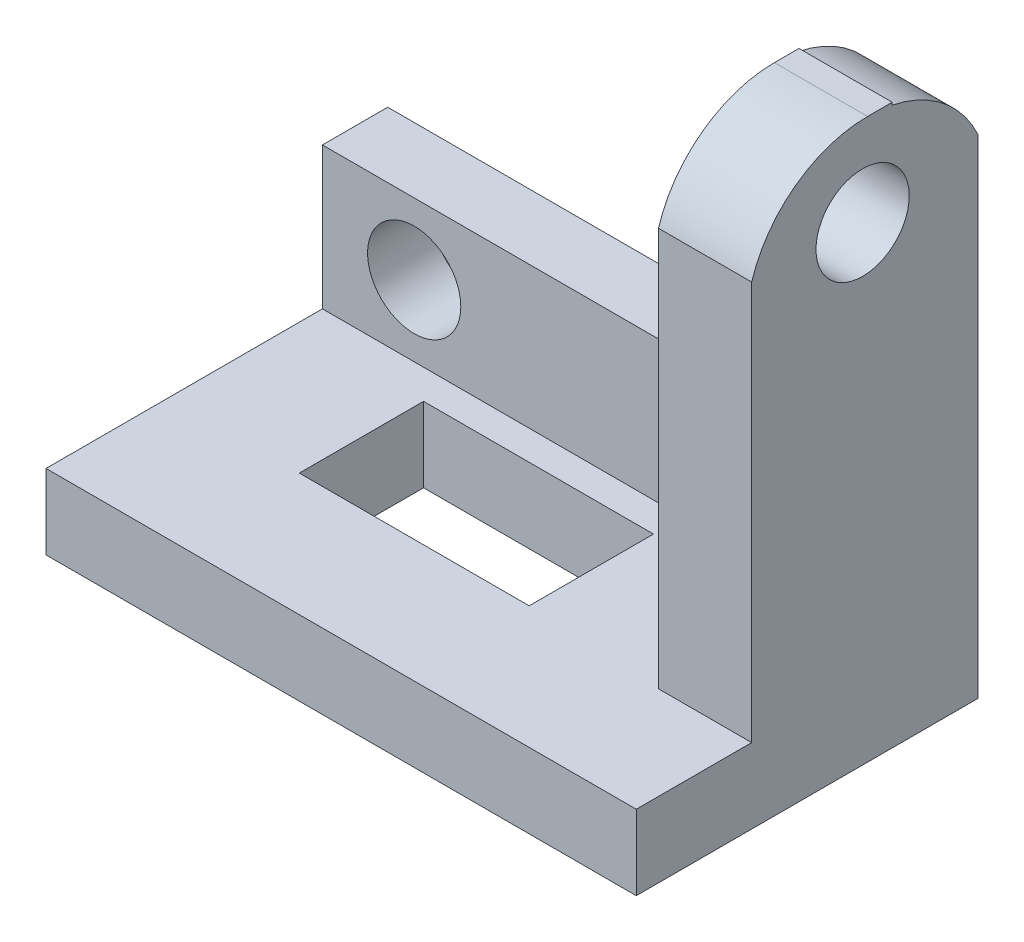
from build123d import *

# Parameters (mm, degrees)
SKETCH9_W           = 95
SKETCH9_H           = 55
BOSS_EXTRUDE1_DEPTH = 90
CUT_EXTRUDE5_DEPTH  = 100
SKETCH12_W          = 60.486878253
SKETCH12_H          = 73.853608548
CUT_EXTRUDE7_DEPTH  = 80
SKETCH13_W          = 80
SKETCH13_H          = 25.917714192
CUT_EXTRUDE8_DEPTH  = 22.845479
FILLET1_R           = 20
SKETCH16_R          = 7.5
CUT_EXTRUDE9_DEPTH  = 30
SKETCH17_W          = 37
SKETCH17_H          = 20
CUT_EXTRUDE10_DEPTH = 30
SKETCH18_R          = 7.5
CUT_EXTRUDE11_DEPTH = 30


with BuildPart() as part:
    # Sketch9 → Boss-Extrude1 (new body)
    with BuildSketch(Plane(origin=(0, 0, 0), x_dir=(1, 0, 0), z_dir=(0, 1, 0))):
        with Locations((9.391117479, -20.408309456)):
            Rectangle(SKETCH9_W, SKETCH9_H)
    extrude(amount=-BOSS_EXTRUDE1_DEPTH)

    # Sketch10 → Cut-Extrude5 (cut)
    with BuildSketch(Plane(origin=(56.891117479, 0, 0), x_dir=(0, 0, -1), z_dir=(1, 0, 0))):
        with BuildLine():
            ThreePointArc((-6.717440326, -0.405285552), (1.502612431, -4.261054452), (7.091690544, -11.416362061))
            Line((7.091690544, -11.416362061), (7.091690544, 0))
            Line((7.091690544, 0), (-6.717440326, 0))
            Line((-6.717440326, 0), (-6.717440326, -0.405285552))
        make_face()
        with BuildLine():
            Line((-47.908309456, -77.945973927), (-29.335605617, -77.945973927))
            Line((-29.335605617, -77.945973927), (-29.335605617, -13.754463437))
            ThreePointArc((-29.335605617, -13.754463437), (-22.266542801, -3.810210472), (-10.675938318, 0))
            Line((-10.675938318, 0), (-47.908309456, 0))
            Line((-47.908309456, 0), (-47.908309456, -77.945973927))
        make_face()
    extrude(amount=-CUT_EXTRUDE5_DEPTH, mode=Mode.SUBTRACT)

    # Sketch12 → Cut-Extrude7 (cut)
    with BuildSketch(Plane.ZY.offset(38.108882521)):
        with Locations((7.902207673, -18.173690635)):
            Rectangle(SKETCH12_W, SKETCH12_H)
    extrude(amount=-CUT_EXTRUDE7_DEPTH, mode=Mode.SUBTRACT)

    # Sketch13 → Cut-Extrude8 (cut)
    with BuildSketch(Plane(origin=(0, -55.100494909, 0), x_dir=(1, 0, 0), z_dir=(0, 1, 0))):
        with Locations((1.891117479, -16.376748521)):
            Rectangle(SKETCH13_W, SKETCH13_H)
    extrude(amount=-CUT_EXTRUDE8_DEPTH, mode=Mode.SUBTRACT)

    # Fillet1
    fillet1_edges = [part.edges().sort_by_distance(p)[0] for p in [
        (41.891117479, -55.100494909, -1.836899559),
    ]]
    fillet(fillet1_edges, radius=FILLET1_R)

    # Sketch16 → Cut-Extrude9 (cut)
    with BuildSketch(Plane.XY.offset(3.417891425)):
        with Locations((-23.342301778, -66.523234418)):
            Circle(SKETCH16_R)
        with Locations((27.03315513, -66.523234418)):
            Circle(SKETCH16_R)
    extrude(amount=-CUT_EXTRUDE9_DEPTH, mode=Mode.SUBTRACT)

    # Sketch17 → Cut-Extrude10 (cut)
    with BuildSketch(Plane(origin=(0, -77.945973927, 0), x_dir=(1, 0, 0), z_dir=(0, 1, 0))):
        with Locations((1.421785082, -18.172095262)):
            Rectangle(SKETCH17_W, SKETCH17_H)
    extrude(amount=-CUT_EXTRUDE10_DEPTH, mode=Mode.SUBTRACT)

    # Sketch18 → Cut-Extrude11 (cut)
    with BuildSketch(Plane.ZY.offset(-41.891117479)):
        with Locations((11.481013295, -14.392127448)):
            Circle(SKETCH18_R)
    extrude(amount=-CUT_EXTRUDE11_DEPTH, mode=Mode.SUBTRACT)


solid = part.part
